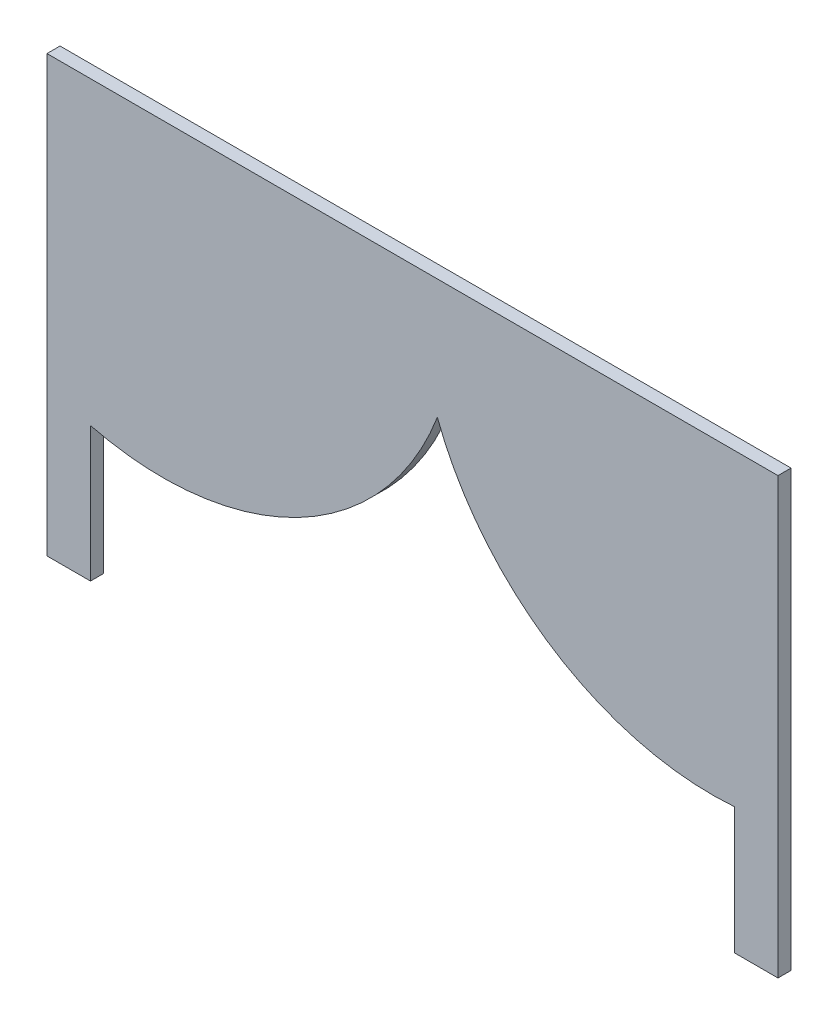
from build123d import *

# Parameters (mm, degrees)
SALIENTE_EXTRUIR1_DEPTH = 3


with BuildPart() as part:
    # Croquis1 → Saliente-Extruir1 (new body)
    with BuildSketch(Plane.XY):
        with BuildLine():
            Line((68.287228231, -24.307780687), (68.287228231, -43.400459387))
            Line((68.287228231, -43.400459387), (68.287228231, -53.400459387))
            Line((68.287228231, -53.400459387), (78.287228231, -53.400459387))
            Line((78.287228231, -53.400459387), (78.287228231, 46.599540613))
            Line((78.287228231, 46.599540613), (-89.712771769, 46.599540613))
            Line((-89.712771769, 46.599540613), (-89.712771769, -53.400459387))
            Line((-89.712771769, -53.400459387), (-79.712771769, -53.400459387))
            Line((-79.712771769, -53.400459387), (-79.712771769, -43.400459387))
            Line((-79.712771769, -43.400459387), (-79.712771769, -22.445940721))
            ThreePointArc((-79.712771769, -22.445940721), (-31.962424833, -16.866365463), (0, 19.045062959))
            ThreePointArc((0, 19.045062959), (26.942806363, -13.973710623), (68.287228231, -24.307780687))
        make_face()
    extrude(amount=SALIENTE_EXTRUIR1_DEPTH)


solid = part.part
